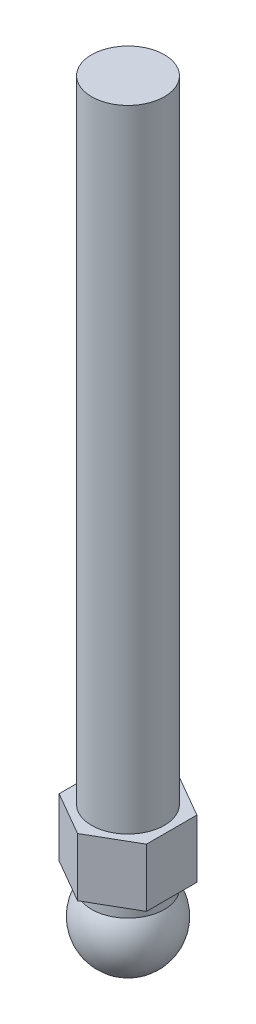
from build123d import *

# Parameters (mm, degrees)
BOSS_EXTRUDE3_DEPTH = 8


with BuildPart() as part:
    # Sketch1 → Revolve1 (revolve)
    with BuildSketch(Plane.XY):
        with BuildLine():
            Line((-5, 3.31662479), (-5, 100))
            Line((-5, 100), (0, 100))
            Line((0, 100), (0, -6))
            ThreePointArc((0, -6), (-5.286764074, -2.837274331), (-5, 3.31662479))
        make_face()
    revolve(axis=Axis((0, 109.494581108, 0), (0, -1, 0)))

    # Sketch4 → Boss-Extrude3 (add)
    with BuildSketch(Plane(origin=(0, 5.31662479, 0), x_dir=(1, 0, 0), z_dir=(0, 1, 0))):
        Polygon((0, 6.92820323), (-6, 3.464101615), (-6, -3.464101615), (0, -6.92820323), (6, -3.464101615), (6, 3.464101615), align=None)
    extrude(amount=BOSS_EXTRUDE3_DEPTH)


solid = part.part
